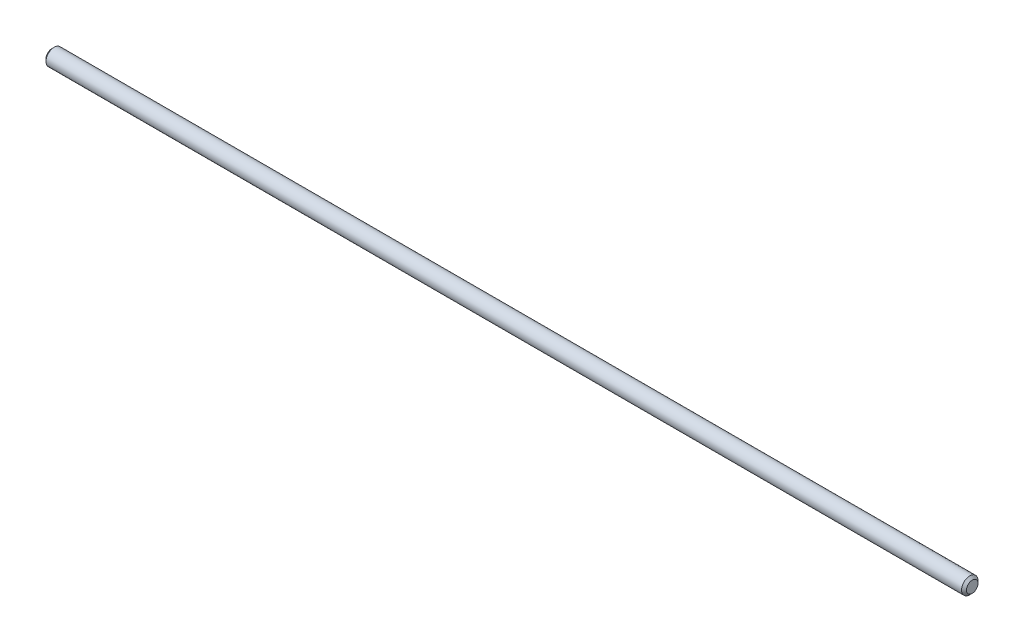
from build123d import *

# Parameters (mm, degrees)
SKETCH2_R                = 3.175
BOSS_EXTRUDE1_DEPTH      = 177.8
BOSS_EXTRUDE1_DEPTH_BACK = 177.8
CHAMFER1_SIZE            = 0.9525


with BuildPart() as part:
    # Sketch2 → Boss-Extrude1 (new body, two sides)
    with BuildSketch(Plane(origin=(0, 0, 0), x_dir=(0, 0, -1), z_dir=(1, 0, 0))) as boss_extrude1_sk:
        Circle(SKETCH2_R)
    extrude(amount=BOSS_EXTRUDE1_DEPTH)
    extrude(boss_extrude1_sk.sketch, amount=-BOSS_EXTRUDE1_DEPTH_BACK)

    # Chamfer1
    chamfer1_edges = [part.edges().sort_by_distance(p)[0] for p in [
        (-177.8, 0, 3.175),
        (177.8, 0, 3.175),
    ]]
    chamfer(chamfer1_edges, length=CHAMFER1_SIZE)


solid = part.part
